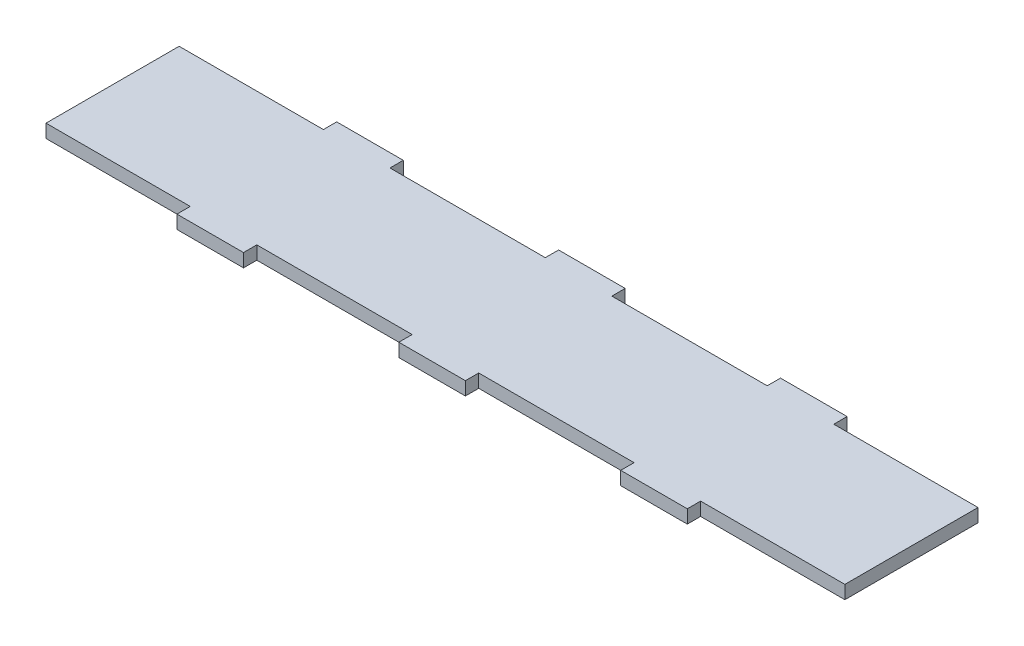
from build123d import *

# Parameters (mm, degrees)
RESSALTO_EXTRUS_O1_DEPTH = 6


with BuildPart() as part:
    # Esboço1 → Ressalto-extrusão1 (new body)
    with BuildSketch(Plane(origin=(0, 0, 0), x_dir=(1, 0, 0), z_dir=(0, 1, 0))):
        Polygon((15, 0), (-15, 0), (-15, 6), (-85, 6), (-85, 0), (-115, 0), (-115, 6), (-180, 6), (-180, 66), (-115, 66), (-115, 72), (-85, 72), (-85, 66), (-15, 66), (-15, 72), (15, 72), (15, 66), (85, 66), (85, 72), (115, 72), (115, 66), (180, 66), (180, 6), (115, 6), (115, 0), (85, 0), (85, 6), (15, 6), align=None)
    extrude(amount=RESSALTO_EXTRUS_O1_DEPTH)


solid = part.part
